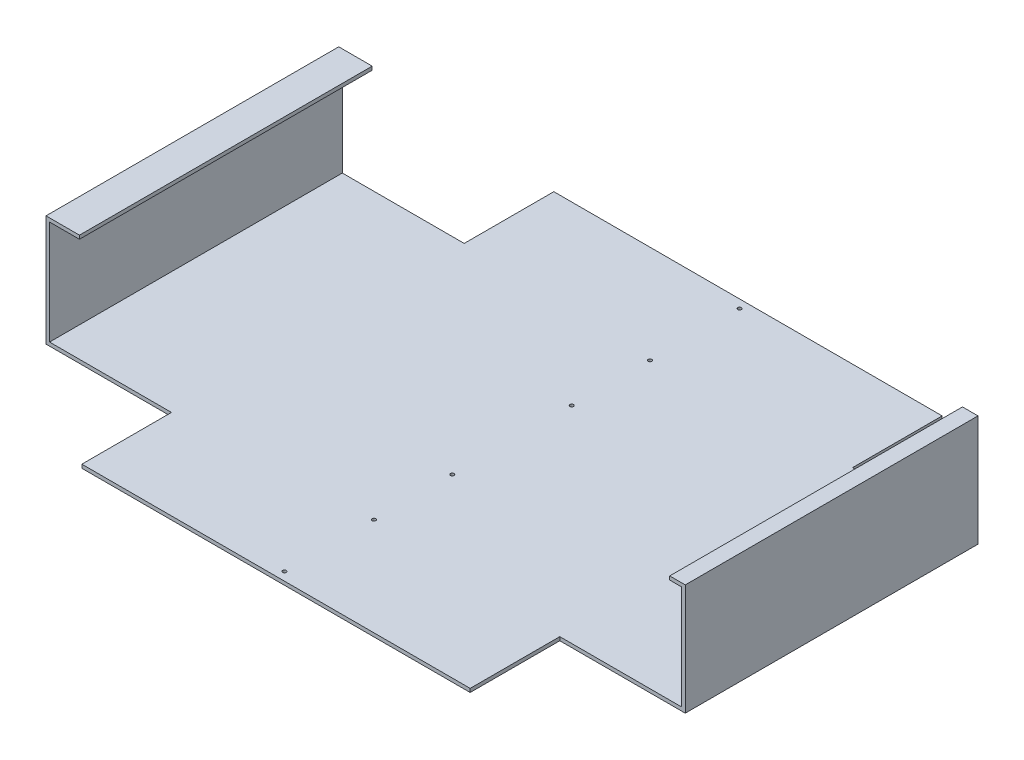
from build123d import *

# Parameters (mm, degrees)
SKETCH1_W               = 535
SKETCH1_H               = 395
BOSS_EXTRUDE1_DEPTH     = 3
SKETCH2_W               = 105
SKETCH2_H               = 75
CUT_EXTRUDE1_DEPTH      = 3
MIRROR2_COPY_1_SKETCH_W = 105
MIRROR2_COPY_1_SKETCH_H = 75
MIRROR2_COPY_1_DEPTH    = 3
SKETCH3_W               = 3
SKETCH3_H               = 245
BOSS_EXTRUDE2_DEPTH     = 90
SKETCH4_W               = 245
SKETCH4_H               = 3
BOSS_EXTRUDE3_DEPTH     = 25
SKETCH5_W               = 3
SKETCH5_H               = 245
BOSS_EXTRUDE4_DEPTH     = 90
SKETCH6_W               = 245
SKETCH6_H               = 3
BOSS_EXTRUDE5_DEPTH     = 10
SKETCH7_R               = 1.5
CUT_EXTRUDE2_DEPTH      = 3
SKETCH8_R               = 1.5
CUT_EXTRUDE3_DEPTH      = 4
SKETCH9_R               = 1.5
CUT_EXTRUDE4_DEPTH      = 4


with BuildPart() as part:
    # Sketch1 → Boss-Extrude1 (new body)
    with BuildSketch(Plane(origin=(0, 0, 0), x_dir=(1, 0, 0), z_dir=(0, 1, 0))):
        Rectangle(SKETCH1_W, SKETCH1_H)
    extrude(amount=BOSS_EXTRUDE1_DEPTH)

    # Sketch2 → Cut-Extrude1 (cut)
    with BuildSketch(Plane(origin=(0, 3, 0), x_dir=(1, 0, 0), z_dir=(0, 1, 0))):
        with Locations((-215, 160)):
            Rectangle(SKETCH2_W, SKETCH2_H)
    cut_extrude1 = extrude(amount=-CUT_EXTRUDE1_DEPTH, mode=Mode.SUBTRACT)

    # Mirror1: Cut-Extrude1 across plane
    add(cut_extrude1.mirror(Plane.XY), mode=Mode.SUBTRACT)

    # Mirror2: Cut-Extrude1 across plane
    add(cut_extrude1.mirror(Plane(origin=(0, 0, 0), x_dir=(0, 0, 1), z_dir=(1, 0, 0))), mode=Mode.SUBTRACT)

    # Mirror2 copy 1 sketch → Mirror2 copy 1 (cut)
    with BuildSketch(Plane(origin=(0, 3, 0), x_dir=(-1, 0, 0), z_dir=(0, 1, 0))):
        with Locations((-215, 160)):
            Rectangle(MIRROR2_COPY_1_SKETCH_W, MIRROR2_COPY_1_SKETCH_H)
    extrude(amount=-MIRROR2_COPY_1_DEPTH, mode=Mode.SUBTRACT)

    # Sketch3 → Boss-Extrude2 (add)
    with BuildSketch(Plane(origin=(0, 3, 0), x_dir=(1, 0, 0), z_dir=(0, 1, 0))):
        with Locations((-266, 0)):
            Rectangle(SKETCH3_W, SKETCH3_H)
    extrude(amount=BOSS_EXTRUDE2_DEPTH)

    # Sketch4 → Boss-Extrude3 (add)
    with BuildSketch(Plane(origin=(-264.5, 0, 0), x_dir=(0, 0, -1), z_dir=(1, 0, 0))):
        with Locations((0, 91.5)):
            Rectangle(SKETCH4_W, SKETCH4_H)
    extrude(amount=BOSS_EXTRUDE3_DEPTH)

    # Sketch5 → Boss-Extrude4 (add)
    with BuildSketch(Plane(origin=(0, 3, 0), x_dir=(1, 0, 0), z_dir=(0, 1, 0))):
        with Locations((266, 0)):
            Rectangle(SKETCH5_W, SKETCH5_H)
    extrude(amount=BOSS_EXTRUDE4_DEPTH)

    # Sketch6 → Boss-Extrude5 (add)
    with BuildSketch(Plane.ZY.offset(-264.5)):
        with Locations((0, 91.5)):
            Rectangle(SKETCH6_W, SKETCH6_H)
    extrude(amount=BOSS_EXTRUDE5_DEPTH)

    # Sketch7 → Cut-Extrude2 (cut)
    with BuildSketch(Plane(origin=(0, 3, 0), x_dir=(1, 0, 0), z_dir=(0, 1, 0))):
        with Locations((0, 50)):
            Circle(SKETCH7_R)
        with Locations((0, -50)):
            Circle(SKETCH7_R)
    extrude(amount=-CUT_EXTRUDE2_DEPTH, mode=Mode.SUBTRACT)

    # Sketch8 → Cut-Extrude3 (cut, through all)
    with BuildSketch(Plane(origin=(0, 3, 0), x_dir=(1, 0, 0), z_dir=(0, 1, 0))):
        with Locations((0, -190.5)):
            Circle(SKETCH8_R)
    cut_extrude3 = extrude(amount=-CUT_EXTRUDE3_DEPTH, mode=Mode.SUBTRACT)

    # Sketch9 → Cut-Extrude4 (cut, through all)
    with BuildSketch(Plane(origin=(0, 3, 0), x_dir=(1, 0, 0), z_dir=(0, 1, 0))):
        with Locations((0, -115.5)):
            Circle(SKETCH9_R)
    cut_extrude4 = extrude(amount=-CUT_EXTRUDE4_DEPTH, mode=Mode.SUBTRACT)

    # Mirror3: Cut-Extrude3, Cut-Extrude4 across plane
    add(cut_extrude3.mirror(Plane.XY), mode=Mode.SUBTRACT)
    add(cut_extrude4.mirror(Plane.XY), mode=Mode.SUBTRACT)


solid = part.part
